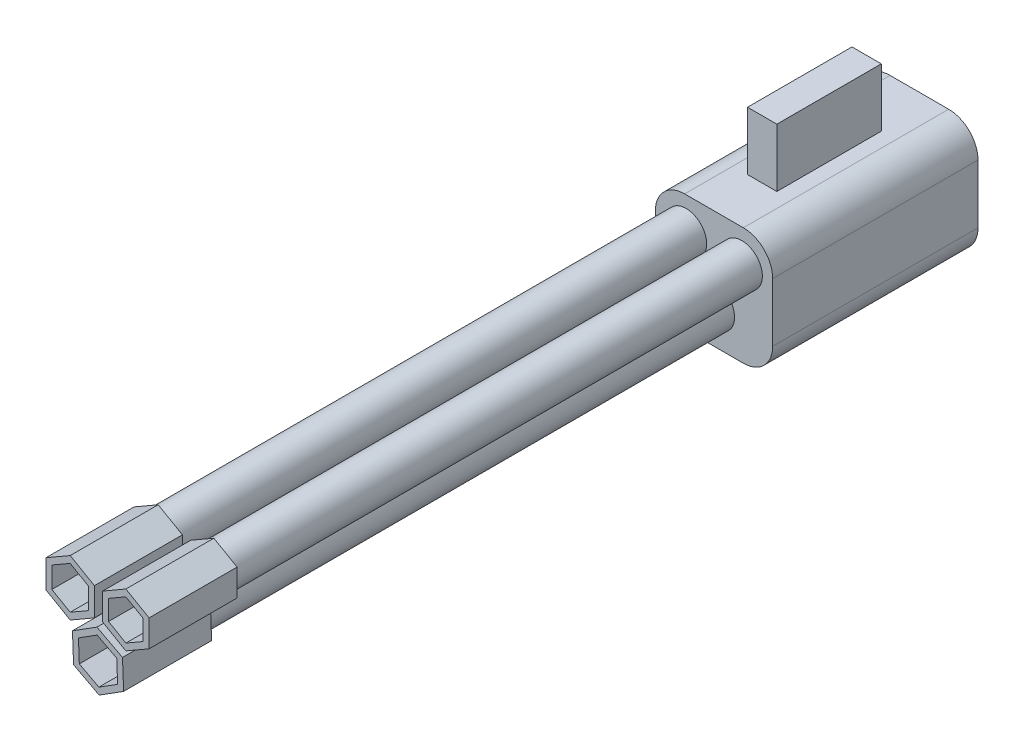
from build123d import *

# Parameters (mm, degrees)
IZIM1_W                          = 4
IZIM1_H                          = 4
Y_KSEKLIK_EKSTR_ZYON1_DEPTH      = 7
RADYUS1_R                        = 1
RADYUS2_R                        = 1
RADYUS3_R                        = 1
RADYUS4_R                        = 1
IZIM3_R                          = 0.7
IZIM3_R_2                        = 0.5
EKSTR_ZYON_NCE1_DEPTH            = 18
IZIM6_W                          = 3.561558411
IZIM6_H                          = 1.988004136
Y_KSEKLIK_EKSTR_ZYON2_DEPTH      = 0.5
Y_KSEKLIK_EKSTR_ZYON2_DEPTH_BACK = 0.5
EKSTR_ZYON_NCE3_DEPTH            = 3


with BuildPart() as part:
    # Çizim1 → Yükseklik-Ekstrüzyon1 (new body)
    with BuildSketch(Plane.XY):
        with Locations((0, -0.353018955)):
            Rectangle(IZIM1_W, IZIM1_H)
    extrude(amount=Y_KSEKLIK_EKSTR_ZYON1_DEPTH)

    # Radyus1
    radyus1_edges = [part.edges().sort_by_distance(p)[0] for p in [
        (2, -2.353018955, 3.5),
    ]]
    fillet(radyus1_edges, radius=RADYUS1_R)

    # Radyus2
    radyus2_edges = [part.edges().sort_by_distance(p)[0] for p in [
        (-2, 1.646981045, 3.5),
    ]]
    fillet(radyus2_edges, radius=RADYUS2_R)

    # Radyus3
    radyus3_edges = [part.edges().sort_by_distance(p)[0] for p in [
        (2, 1.646981045, 3.5),
    ]]
    fillet(radyus3_edges, radius=RADYUS3_R)

    # Radyus4
    radyus4_edges = [part.edges().sort_by_distance(p)[0] for p in [
        (-2, -2.353018955, 3.5),
    ]]
    fillet(radyus4_edges, radius=RADYUS4_R)

    # Çizim3 → Ekstrüzyon-İnce1 (add)
    with BuildSketch(Plane.XY.offset(7)):
        with Locations((-0.949214627, 0.542466542)):
            Circle(IZIM3_R)
        with Locations((-0.949214627, 0.542466542)):
            Circle(IZIM3_R_2, mode=Mode.SUBTRACT)
        with Locations((0.949214627, 0.542466542)):
            Circle(IZIM3_R)
        with Locations((0.949214627, 0.542466542)):
            Circle(IZIM3_R_2, mode=Mode.SUBTRACT)
        with Locations((0, -1.147016096)):
            Circle(IZIM3_R)
        with Locations((0, -1.147016096)):
            Circle(IZIM3_R_2, mode=Mode.SUBTRACT)
    extrude(amount=EKSTR_ZYON_NCE1_DEPTH)

    # Çizim6 → Yükseklik-Ekstrüzyon2 (add, two sides)
    with BuildSketch(Plane(origin=(0, 0, 0), x_dir=(0, 0, -1), z_dir=(1, 0, 0))) as y_kseklik_ekstr_zyon2_sk:
        with Locations((-3.576903913, 2.640983113)):
            Rectangle(IZIM6_W, IZIM6_H)
    extrude(amount=Y_KSEKLIK_EKSTR_ZYON2_DEPTH)
    extrude(y_kseklik_ekstr_zyon2_sk.sketch, amount=-Y_KSEKLIK_EKSTR_ZYON2_DEPTH_BACK)

    # Çizim4 → Ekstrüzyon-İnce3 (add)
    with BuildSketch(Plane.XY.offset(25)):
        Polygon((-0.949214627, -0.409912915), (-0.124429823, 0.066276814), (-0.124429823, 1.018656271), (-0.949214627, 1.494845999), (-1.773999431, 1.018656271), (-1.773999431, 0.066276814), align=None)
        Polygon((-0.949214627, -0.178972807), (-0.324429823, 0.181746867), (-0.324429823, 0.903186217), (-0.949214627, 1.263905891), (-1.573999431, 0.903186217), (-1.573999431, 0.181746867), align=None, mode=Mode.SUBTRACT)
        Polygon((0.949214627, -0.371158962), (1.740437522, 0.08565379), (1.740437522, 0.999279294), (0.949214627, 1.456092046), (0.157991731, 0.999279294), (0.157991731, 0.08565379), align=None)
        Polygon((0.949214627, -0.140218854), (1.540437522, 0.201123844), (1.540437522, 0.88380924), (0.949214627, 1.225151938), (0.357991731, 0.88380924), (0.357991731, 0.201123844), align=None, mode=Mode.SUBTRACT)
        Polygon((0.871605884, -1.606698651), (0.833899712, -0.622024536), (-0.037706171, -0.162341981), (-0.871605884, -0.687333541), (-0.833899712, -1.672007655), (0.037706171, -2.131690211), align=None)
        Polygon((0.667333897, -1.498966164), (0.638464649, -0.745063023), (-0.028869248, -0.393112954), (-0.667333897, -0.795066027), (-0.638464649, -1.548969169), (0.028869248, -1.900919237), align=None, mode=Mode.SUBTRACT)
    extrude(amount=EKSTR_ZYON_NCE3_DEPTH)


solid = part.part
